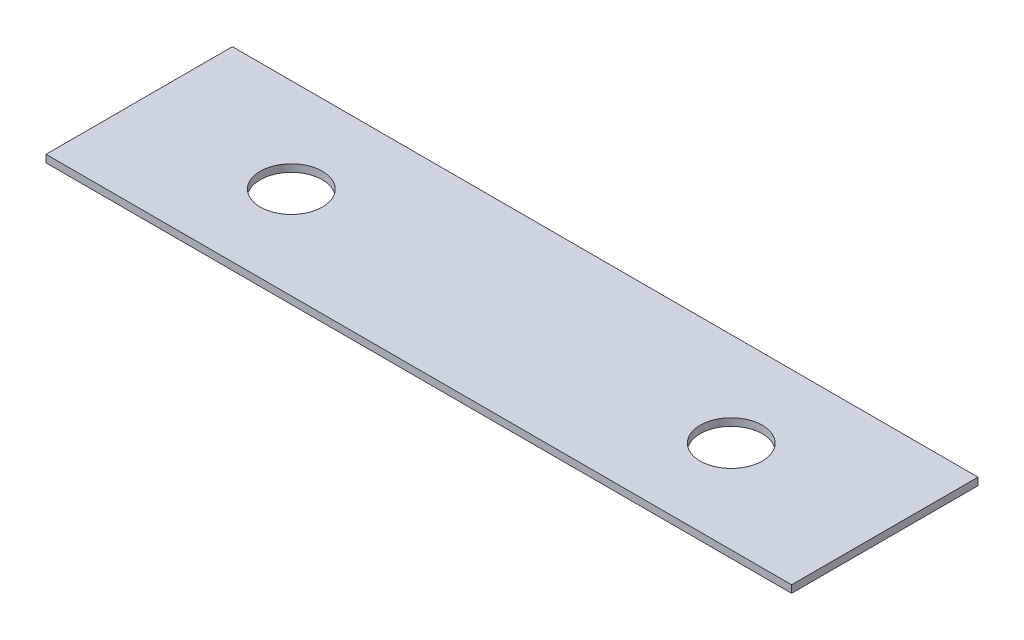
from build123d import *

# Parameters (mm, degrees)
SKETCH1_W           = 38.1
SKETCH1_H           = 1.51892
BOSS_EXTRUDE1_DEPTH = 152.4
CUT_EXTRUDE1_REACH  = 3.519
SKETCH2_R           = 6.35


with BuildPart() as part:
    # Sketch1 → Boss-Extrude1 (new body)
    with BuildSketch(Plane(origin=(0, 0, 0), x_dir=(0, 0, -1), z_dir=(1, 0, 0))):
        with Locations((19.05, 0.75946)):
            Rectangle(SKETCH1_W, SKETCH1_H)
    extrude(amount=BOSS_EXTRUDE1_DEPTH)

    # Sketch2 → Cut-Extrude1 (cut, up to next)
    with BuildSketch(Plane(origin=(0, 1.51892, 0), x_dir=(1, 0, 0), z_dir=(0, 1, 0)), mode=Mode.PRIVATE) as cut_extrude1_sk1:
        with Locations((31.242, 18.9)):
            Circle(SKETCH2_R)
    cut_extrude1_tool1 = extrude(cut_extrude1_sk1.sketch, amount=-CUT_EXTRUDE1_REACH, mode=Mode.PRIVATE) & part.part
    add(cut_extrude1_tool1.solids().sort_by_distance((31.242, 1.51892, -18.9))[0], mode=Mode.SUBTRACT)
    # Sketch2 → Cut-Extrude1 (cut, up to next)
    with BuildSketch(Plane(origin=(0, 1.51892, 0), x_dir=(1, 0, 0), z_dir=(0, 1, 0)), mode=Mode.PRIVATE) as cut_extrude1_sk2:
        with Locations((121.158, 18.9)):
            Circle(SKETCH2_R)
    cut_extrude1_tool2 = extrude(cut_extrude1_sk2.sketch, amount=-CUT_EXTRUDE1_REACH, mode=Mode.PRIVATE) & part.part
    add(cut_extrude1_tool2.solids().sort_by_distance((121.158, 1.51892, -18.9))[0], mode=Mode.SUBTRACT)


solid = part.part
